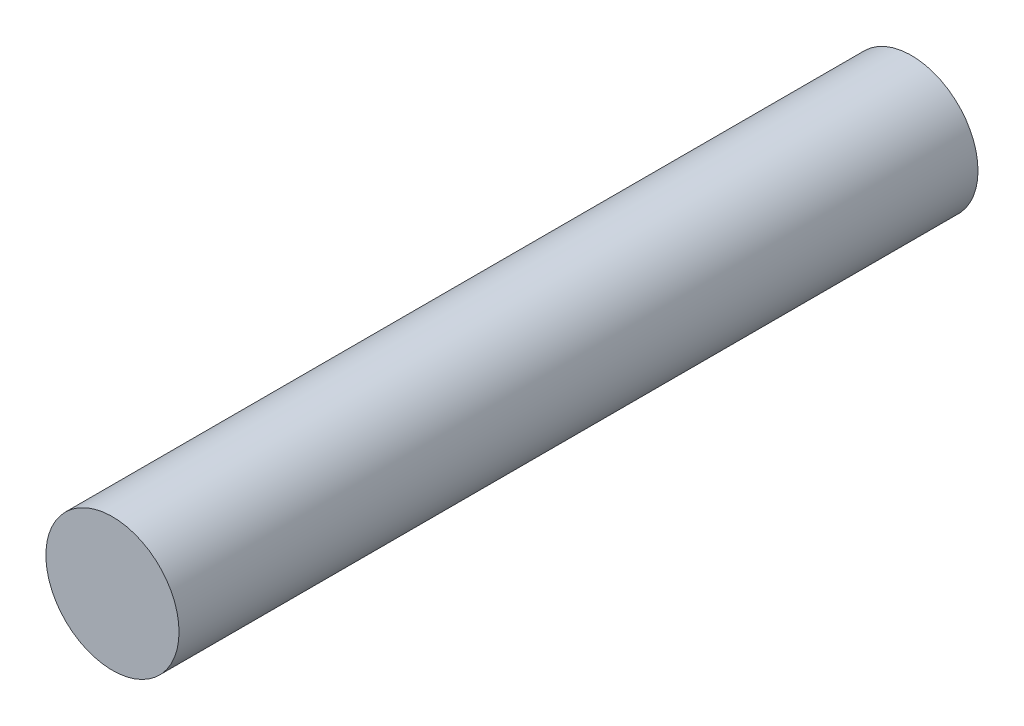
from build123d import *

# Parameters (mm, degrees)
SKETCH1_R           = 1.25
BOSS_EXTRUDE1_DEPTH = 15


with BuildPart() as part:
    # Sketch1 → Boss-Extrude1 (new body)
    with BuildSketch(Plane.XY):
        Circle(SKETCH1_R)
    extrude(amount=BOSS_EXTRUDE1_DEPTH)


solid = part.part
